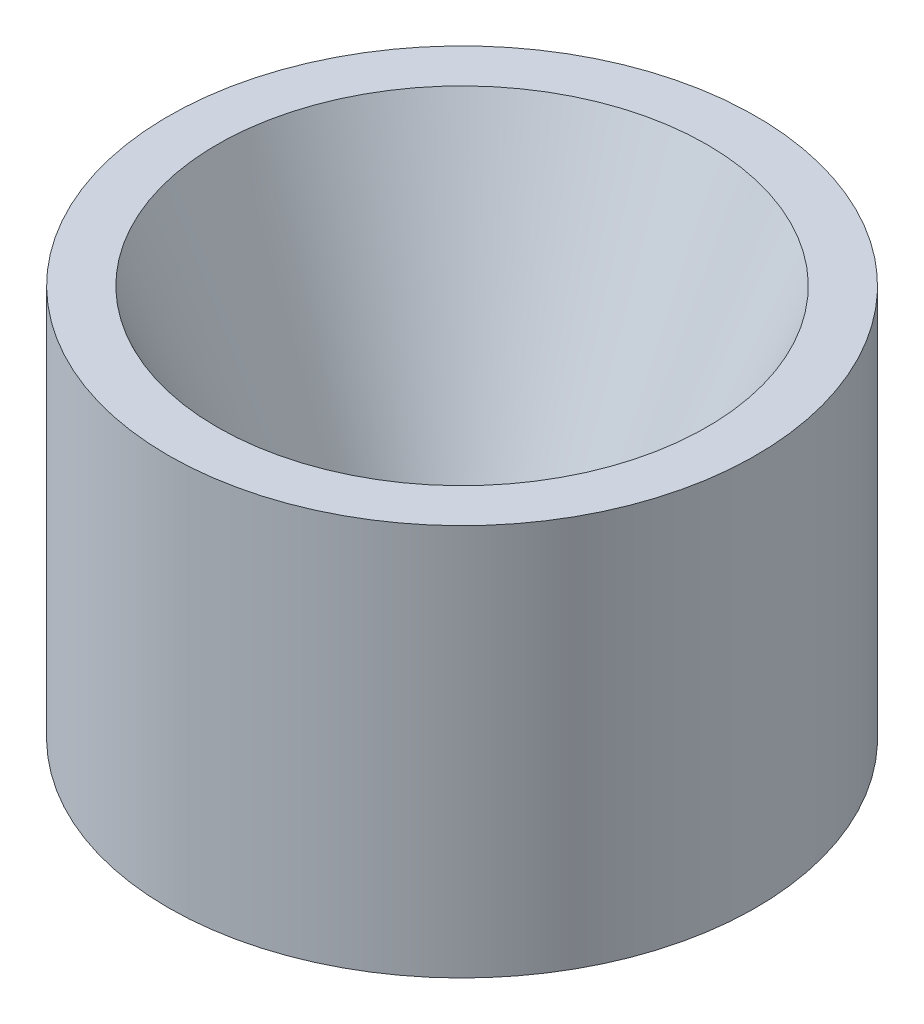
from build123d import *


with BuildPart() as part:
    # Croquis1 → Revolución2 (revolve)
    with BuildSketch(Plane.XY):
        Polygon((1.3, 2.874516361), (3, 2.874516361), (3, 6.874516361), (2.5, 6.874516361), (1, 3.374516361), (1, 3.287430937), align=None)
    revolve(axis=Axis((0, 6.886363636, 0), (0, -1, 0)))


solid = part.part
